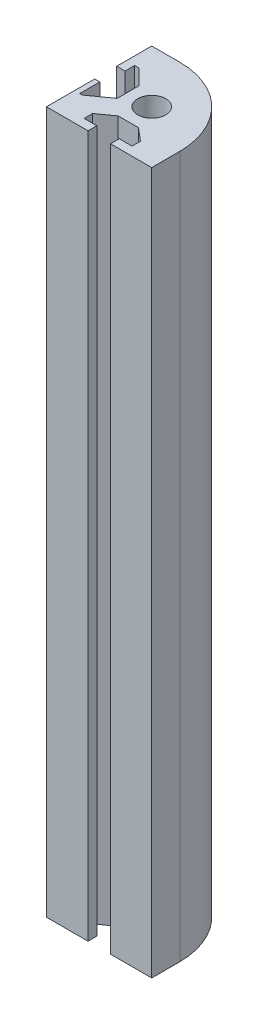
from build123d import *

# Parameters (mm, degrees)
CROQUIS1_R              = 4
SALIENTE_EXTRUIR1_DEPTH = 200


with BuildPart() as part:
    # Croquis1 → Saliente-Extruir1 (new body)
    with BuildSketch(Plane(origin=(0, 0, 0), x_dir=(1, 0, 0), z_dir=(0, 1, 0))):
        with BuildLine():
            Line((-7, 15), (-15, 15))
            Line((-15, 15), (-15, 5.027604917))
            Line((-15, 5.027604917), (-12.623437069, 5.027604917))
            Line((-12.623437069, 5.027604917), (-12.623437069, 7.752682341))
            Line((-12.623437069, 7.752682341), (-11.320548438, 7.752682341))
            Line((-11.320548438, 7.752682341), (-7, 3.432133903))
            Line((-7, 3.432133903), (-7, -2.861090311))
            Line((-7, -2.861090311), (-12.793007796, -7))
            Line((-12.793007796, -7), (-13.527286117, -7))
            Line((-13.527286117, -7), (-13.527286117, -1.25796789))
            Line((-13.527286117, -1.25796789), (-15, -1.25796789))
            Line((-15, -1.25796789), (-15, -15))
            Line((-15, -15), (-3.139941254, -15))
            Line((-3.139941254, -15), (-3.139941254, -12.505835019))
            Line((-3.139941254, -12.505835019), (-6.77895709, -12.505835019))
            Line((-6.77895709, -12.505835019), (-6.77895709, -10.079824462))
            Line((-6.77895709, -10.079824462), (-2.512909638, -7.031876702))
            Line((-2.512909638, -7.031876702), (3.25590476, -7.031876702))
            Line((3.25590476, -7.031876702), (6.894920596, -10.079824462))
            Line((6.894920596, -10.079824462), (6.894920596, -12.505835019))
            Line((6.894920596, -12.505835019), (3.25590476, -12.505835019))
            Line((3.25590476, -12.505835019), (3.25590476, -15))
            Line((3.25590476, -15), (15, -15))
            Line((15, -15), (15, -7))
            ThreePointArc((15, -7), (8.556349186, 8.556349186), (-7, 15))
        make_face()
        Circle(CROQUIS1_R, mode=Mode.SUBTRACT)
    extrude(amount=SALIENTE_EXTRUIR1_DEPTH)


solid = part.part
